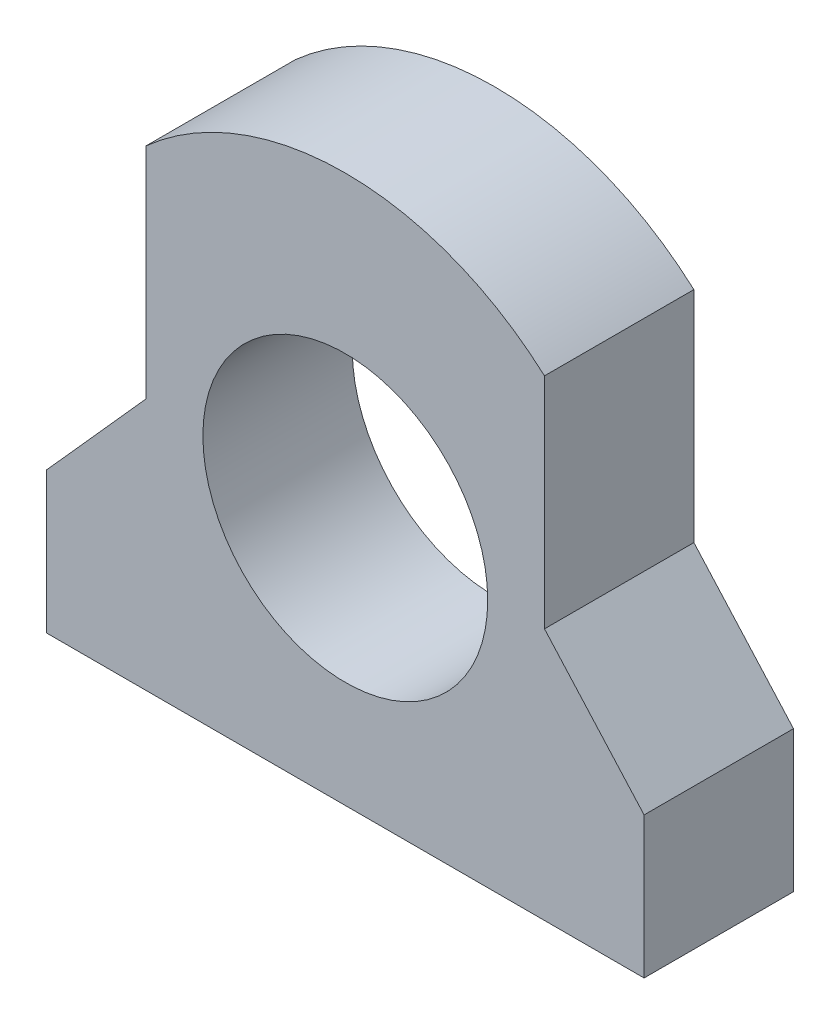
from build123d import *

# Parameters (mm, degrees)
SKETCH1_R           = 14.3
BOSS_EXTRUDE1_DEPTH = 15


with BuildPart() as part:
    # Sketch1 → Boss-Extrude1 (new body)
    with BuildSketch(Plane.XY):
        with BuildLine():
            Line((-30, 0), (30, 0))
            Line((30, 0), (30, 14.180339887))
            Line((30, 14.180339887), (20, 25.360679775))
            Line((20, 25.360679775), (20, 47.360679775))
            ThreePointArc((20, 47.360679775), (0, 55), (-20, 47.360679775))
            Line((-20, 47.360679775), (-20, 25.360679775))
            Line((-20, 25.360679775), (-30, 14.180339887))
            Line((-30, 14.180339887), (-30, 0))
        make_face()
        with Locations((0, 25)):
            Circle(SKETCH1_R, mode=Mode.SUBTRACT)
    extrude(amount=BOSS_EXTRUDE1_DEPTH)


solid = part.part
